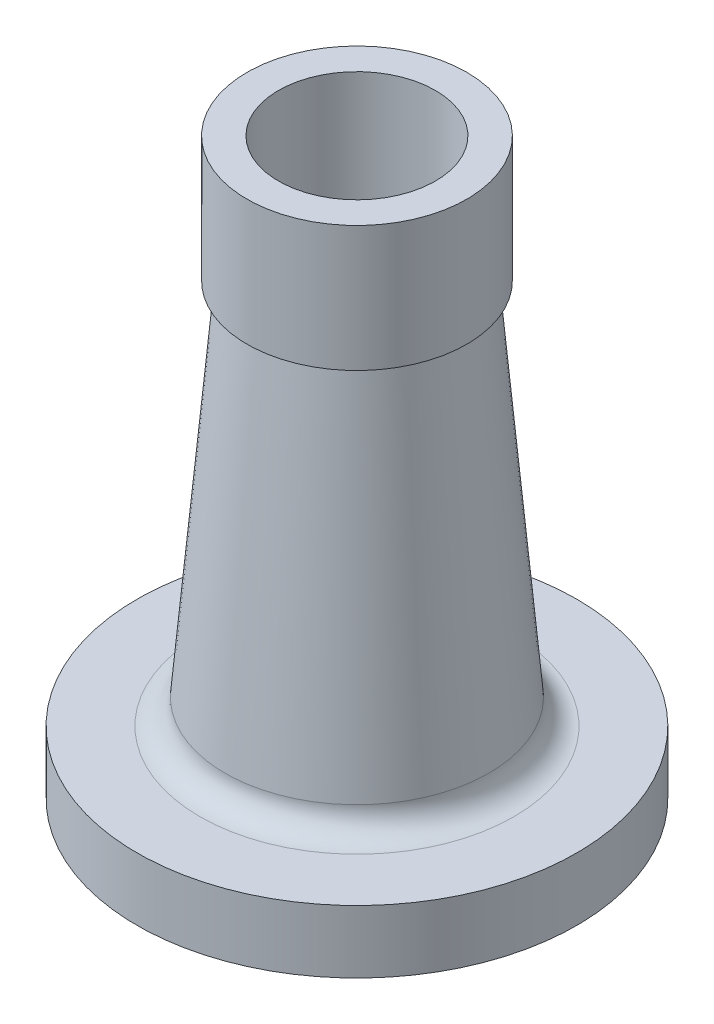
from build123d import *

# Parameters (mm, degrees)
FILLET1_R = 1.5


with BuildPart() as part:
    # Sketch1 → Revolve1 (revolve)
    with BuildSketch(Plane.XY):
        with BuildLine():
            Line((29.062623268, -28.998781924), (35, -87.278860618))
            Line((35, -87.278860618), (50, -87.278860618))
            Line((50, -87.278860618), (50, -90.278860618))
            Line((50, -90.278860618), (70, -90.278860618))
            Line((70, -90.278860618), (70, -70.278860618))
            Line((70, -70.278860618), (50, -70.278860618))
            ThreePointArc((50, -70.278860618), (44.343145751, -67.935714867), (42, -62.278860618))
            Line((42, -62.278860618), (32, 52.5))
            Line((32, 52.5), (35, 52.5))
            Line((35, 52.5), (35, 92.5))
            Line((35, 92.5), (25, 92.5))
            Line((25, 92.5), (25, 17.342006044))
            Line((25, 17.342006044), (29.062623268, -28.998781924))
        make_face()
    revolve(axis=Axis((0, -90.278860618, 0), (0, 1, 0)))

    # Fillet1
    fillet1_edges = [part.edges().sort_by_distance(p)[0] for p in [
        (-50, -87.278860618, 0),
    ]]
    fillet(fillet1_edges, radius=FILLET1_R)


solid = part.part
